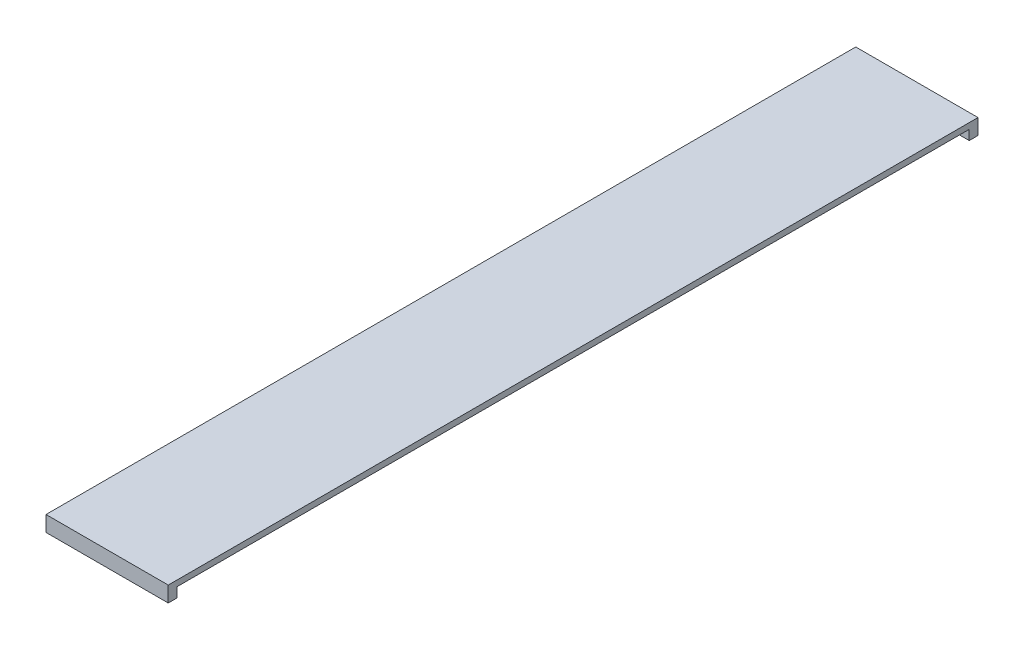
from build123d import *

# Parameters (mm, degrees)
BOSS_EXTRUDE1_DEPTH = 398.78


with BuildPart() as part:
    # Sketch1 → Boss-Extrude1 (new body)
    with BuildSketch(Plane(origin=(0, 0, 0), x_dir=(0, 0, -1), z_dir=(1, 0, 0))):
        Polygon((-1292.225, -31.75), (-1320.8, -31.75), (-1320.8, 19.05), (1320.8, 19.05), (1320.8, -31.75), (1292.225, -31.75), (1292.225, 0), (-1292.225, 0), align=None)
    extrude(amount=BOSS_EXTRUDE1_DEPTH)


solid = part.part
